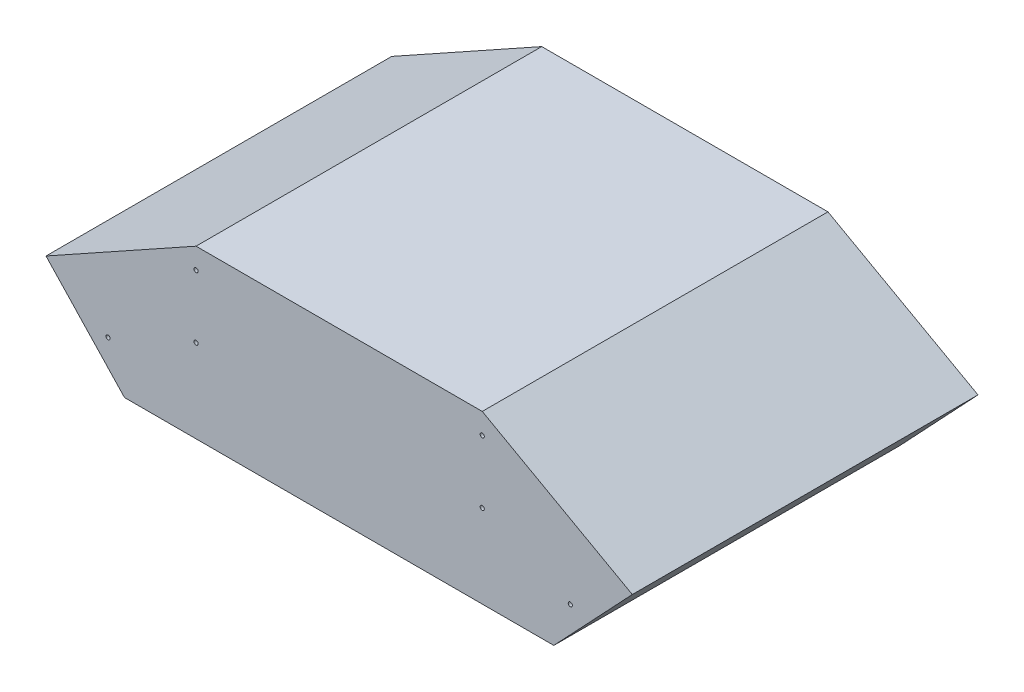
from build123d import *

# Parameters (mm, degrees)
SKETCH_1_R      = 0.82794133
SKETCH_1_R_2    = 1
SKETCH_1_R_3    = 0.3
EXTRUDE_3_DEPTH = 50


with BuildPart() as part:
    # 草图1 → 凸台-拉伸3 (new body)
    with BuildSketch(Plane.XY):
        Polygon((20.69853326, 0), (0, 0), (0, -24.135547841), (31.04779989, -24.135547841), (42.400668091, -12.081204645), align=None)
        with Locations((20.69853326, -12.081204645)):
            Circle(SKETCH_1_R, mode=Mode.SUBTRACT)
        with Locations((33.43169801, -17.796901608)):
            Circle(SKETCH_1_R_2, mode=Mode.SUBTRACT)
        with Locations((20.69853326, -3)):
            Circle(SKETCH_1_R, mode=Mode.SUBTRACT)
        with Locations((33.43169801, -17.796901608)):
            Circle(SKETCH_1_R_2)
        with Locations((33.43169801, -17.796901608)):
            Circle(SKETCH_1_R_3, mode=Mode.SUBTRACT)
        with Locations((20.69853326, -12.081204645)):
            Circle(SKETCH_1_R)
        with Locations((20.69853326, -12.081204645)):
            Circle(SKETCH_1_R_3, mode=Mode.SUBTRACT)
        with Locations((20.69853326, -3)):
            Circle(SKETCH_1_R)
        with Locations((20.69853326, -3)):
            Circle(SKETCH_1_R_3, mode=Mode.SUBTRACT)
        Polygon((0, 0), (-20.69853326, 0), (-42.400668091, -12.081204645), (-31.04779989, -24.135547841), (0, -24.135547841), align=None)
        with Locations((-33.43169801, -17.796901608)):
            Circle(SKETCH_1_R_2, mode=Mode.SUBTRACT)
        with Locations((-20.69853326, -12.081204645)):
            Circle(SKETCH_1_R, mode=Mode.SUBTRACT)
        with Locations((-20.69853326, -3)):
            Circle(SKETCH_1_R, mode=Mode.SUBTRACT)
        with Locations((-33.43169801, -17.796901608)):
            Circle(SKETCH_1_R_2)
        with Locations((-33.43169801, -17.796901608)):
            Circle(SKETCH_1_R_3, mode=Mode.SUBTRACT)
        with Locations((-20.69853326, -12.081204645)):
            Circle(SKETCH_1_R)
        with Locations((-20.69853326, -12.081204645)):
            Circle(SKETCH_1_R_3, mode=Mode.SUBTRACT)
        with Locations((-20.69853326, -3)):
            Circle(SKETCH_1_R)
        with Locations((-20.69853326, -3)):
            Circle(SKETCH_1_R_3, mode=Mode.SUBTRACT)
    extrude(amount=EXTRUDE_3_DEPTH)


solid = part.part
